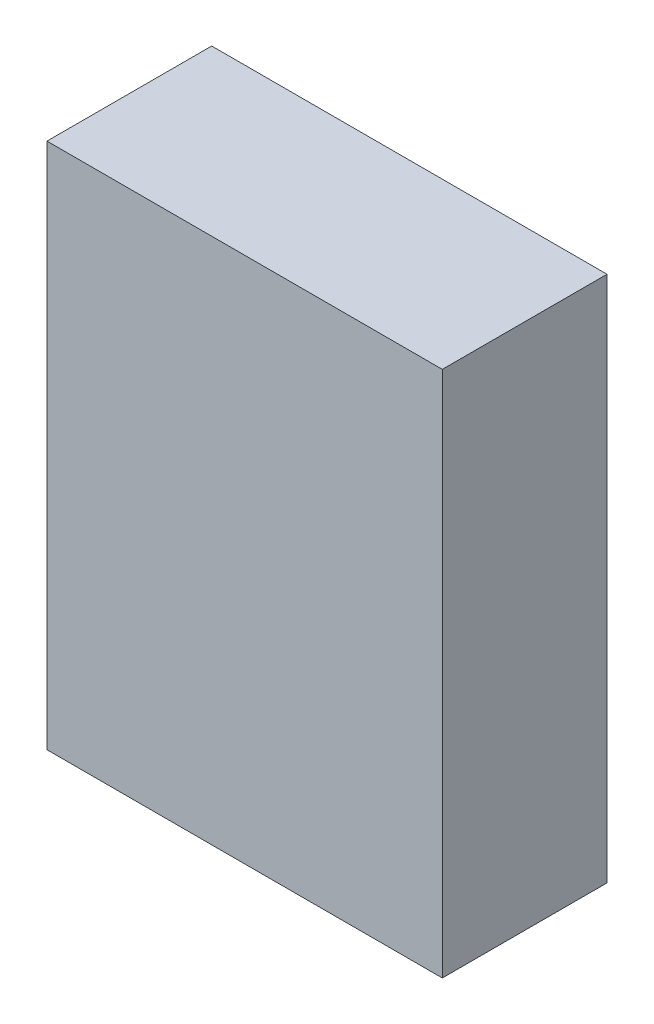
from build123d import *

# Parameters (mm, degrees)
CROQUIS1_W              = 600
CROQUIS1_H              = 800
SALIENTE_EXTRUIR1_DEPTH = 250


with BuildPart() as part:
    # Croquis1 → Saliente-Extruir1 (new body)
    with BuildSketch(Plane.XY):
        Rectangle(CROQUIS1_W, CROQUIS1_H)
    extrude(amount=SALIENTE_EXTRUIR1_DEPTH)


solid = part.part
